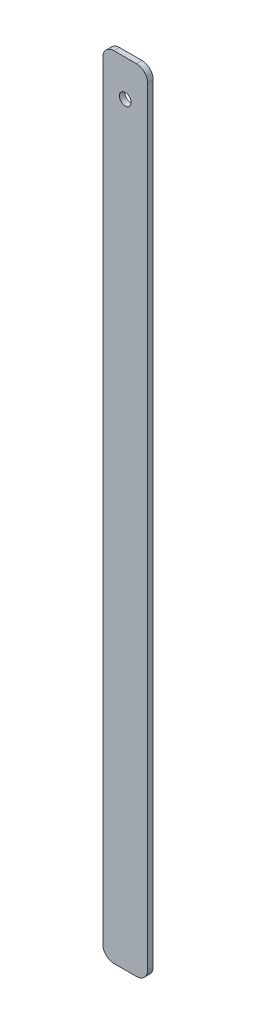
from build123d import *

# Parameters (mm, degrees)
SKETCH2_W           = 8
SKETCH2_H           = 141.2
SKETCH2_R           = 1.05
BOSS_EXTRUDE1_DEPTH = 1
FILLET1_R           = 2


with BuildPart() as part:
    # Sketch2 → Boss-Extrude1 (new body)
    with BuildSketch(Plane.XY):
        with Locations((4, 70.6)):
            Rectangle(SKETCH2_W, SKETCH2_H)
        with Locations((4, 134.7)):
            Circle(SKETCH2_R, mode=Mode.SUBTRACT)
    extrude(amount=BOSS_EXTRUDE1_DEPTH)

    # Fillet1
    fillet1_edges = [part.edges().sort_by_distance(p)[0] for p in [
        (0, 141.2, 0.5),
        (8, 141.2, 0.5),
        (8, 0, 0.5),
        (0, 0, 0.5),
    ]]
    fillet(fillet1_edges, radius=FILLET1_R)


solid = part.part
